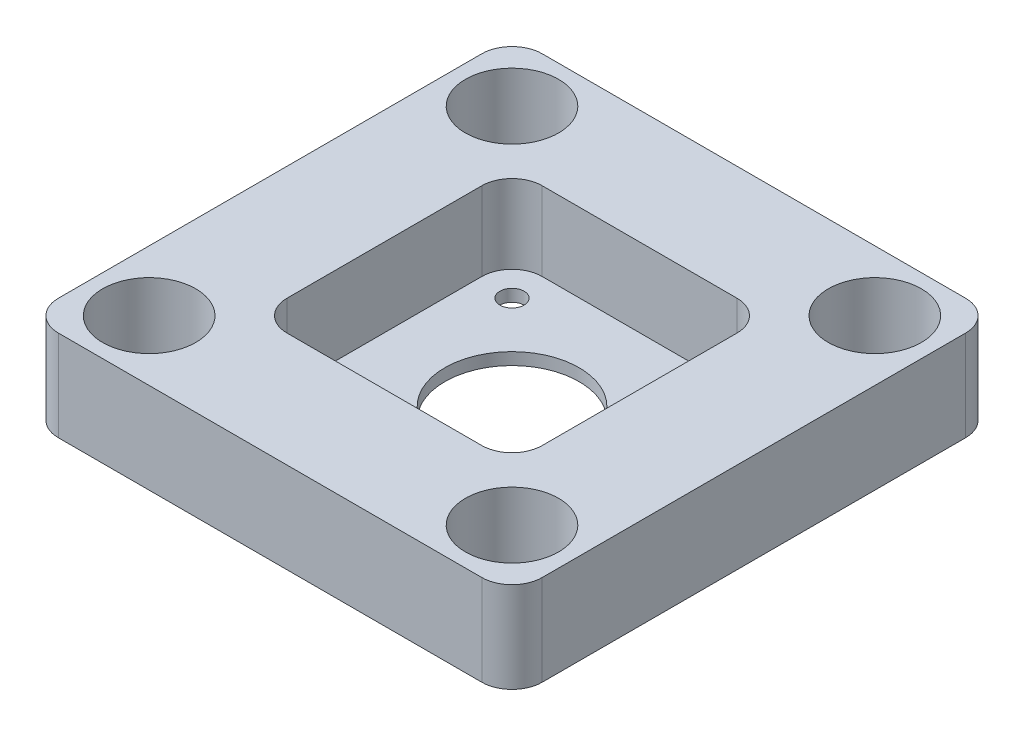
from build123d import *

# Parameters (mm, degrees)
ESBO_O1_W                = 80
ESBO_O1_H                = 80
RESSALTO_EXTRUS_O1_DEPTH = 15
ESBO_O2_W                = 42.2
ESBO_O2_H                = 42.2
CORTE_EXTRUS_O1_DEPTH    = 13
FILETE1_R                = 5
ESBO_O3_R                = 11.1
ESBO_O3_R_2              = 2
CORTE_EXTRUS_O2_DEPTH    = 3
ESBO_O4_R                = 7.7
CORTE_EXTRUS_O3_DEPTH    = 16
FILETE2_R                = 5


with BuildPart() as part:
    # Esboço1 → Ressalto-extrusão1 (new body)
    with BuildSketch(Plane(origin=(0, 0, 0), x_dir=(1, 0, 0), z_dir=(0, 1, 0))):
        Rectangle(ESBO_O1_W, ESBO_O1_H)
    extrude(amount=RESSALTO_EXTRUS_O1_DEPTH)

    # Esboço2 → Corte-extrusão1 (cut)
    with BuildSketch(Plane(origin=(0, 15, 0), x_dir=(1, 0, 0), z_dir=(0, 1, 0))):
        Rectangle(ESBO_O2_W, ESBO_O2_H)
    extrude(amount=-CORTE_EXTRUS_O1_DEPTH, mode=Mode.SUBTRACT)

    # Filete1
    filete1_edges = [part.edges().sort_by_distance(p)[0] for p in [
        (-21.1, 8.5, 21.1),
        (-21.1, 8.5, -21.1),
        (21.1, 8.5, -21.1),
        (21.1, 8.5, 21.1),
    ]]
    fillet(filete1_edges, radius=FILETE1_R)

    # Esboço3 → Corte-extrusão2 (cut, through all)
    with BuildSketch(Plane(origin=(0, 2, 0), x_dir=(1, 0, 0), z_dir=(0, 1, 0))):
        Circle(ESBO_O3_R)
        with Locations((-15.5, 15.5)):
            Circle(ESBO_O3_R_2)
        with Locations((15.5, 15.5)):
            Circle(ESBO_O3_R_2)
        with Locations((15.5, -15.5)):
            Circle(ESBO_O3_R_2)
        with Locations((-15.5, -15.5)):
            Circle(ESBO_O3_R_2)
    extrude(amount=-CORTE_EXTRUS_O2_DEPTH, mode=Mode.SUBTRACT)

    # Esboço4 → Corte-extrusão3 (cut, through all)
    with BuildSketch(Plane(origin=(0, 15, 0), x_dir=(1, 0, 0), z_dir=(0, 1, 0))):
        with Locations((-30, 30)):
            Circle(ESBO_O4_R)
        with Locations((30, 30)):
            Circle(ESBO_O4_R)
        with Locations((30, -30)):
            Circle(ESBO_O4_R)
        with Locations((-30, -30)):
            Circle(ESBO_O4_R)
    extrude(amount=-CORTE_EXTRUS_O3_DEPTH, mode=Mode.SUBTRACT)

    # Filete2
    filete2_edges = [part.edges().sort_by_distance(p)[0] for p in [
        (-40, 7.5, -40),
        (40, 7.5, -40),
        (40, 7.5, 40),
        (-40, 7.5, 40),
    ]]
    fillet(filete2_edges, radius=FILETE2_R)


solid = part.part
